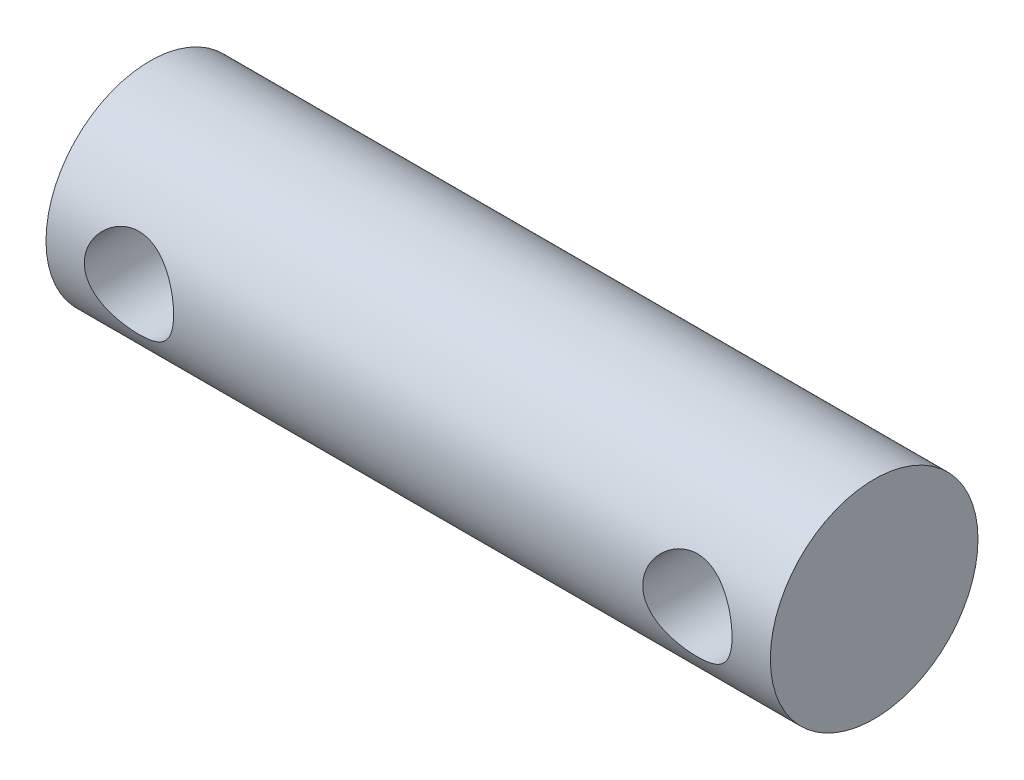
from build123d import *

# Parameters (mm, degrees)
SKETCH1_R                = 5
BOSS_EXTRUDE1_DEPTH      = 23.710000062
BOSS_EXTRUDE1_DEPTH_BACK = 11.170000008
SKETCH2_R                = 2.15
CUT_EXTRUDE1_DEPTH       = 11


with BuildPart() as part:
    # Sketch1 → Boss-Extrude1 (new body, two sides)
    with BuildSketch(Plane(origin=(32.015745885, 0, 0), x_dir=(0, 0, -1), z_dir=(1, 0, 0))) as boss_extrude1_sk:
        with Locations((136.328078847, 49.836172535)):
            Circle(SKETCH1_R)
    extrude(amount=BOSS_EXTRUDE1_DEPTH)
    extrude(boss_extrude1_sk.sketch, amount=-BOSS_EXTRUDE1_DEPTH_BACK)

    # Sketch2 → Cut-Extrude1 (cut, through all)
    with BuildSketch(Plane.XY.offset(-131.328078847)):
        with Locations((51.730745885, 49.836172535)):
            Circle(SKETCH2_R)
        with Locations((24.840753885, 49.836172535)):
            Circle(SKETCH2_R)
    extrude(amount=-CUT_EXTRUDE1_DEPTH, mode=Mode.SUBTRACT)


solid = part.part
